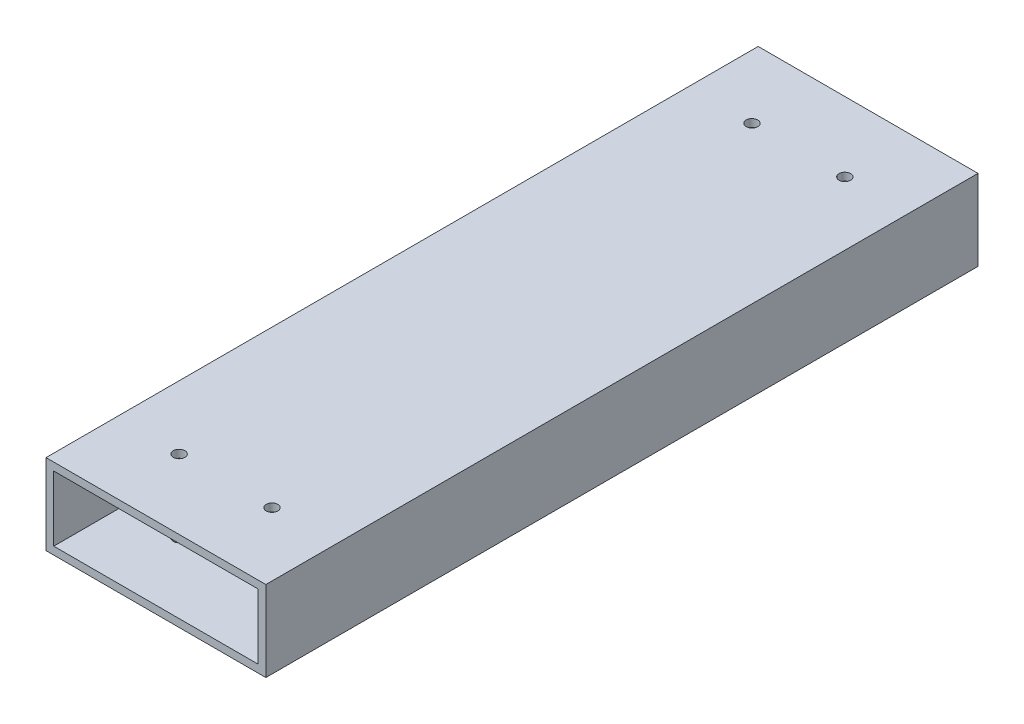
from build123d import *

# Parameters (mm, degrees)
CROQUIS1_W              = 56.8
CROQUIS1_H              = 20.82
SALIENTE_EXTRUIR1_DEPTH = 184
CROQUIS5_W              = 52.8
CROQUIS5_H              = 16.82
CORTAR_EXTRUIR5_DEPTH   = 184
CROQUIS6_R              = 1.5
CORTAR_EXTRUIR6_DEPTH   = 26


with BuildPart() as part:
    # Croquis1 → Saliente-Extruir1 (new body)
    with BuildSketch(Plane.XY):
        with Locations((8.738488477, -207.47377213)):
            Rectangle(CROQUIS1_W, CROQUIS1_H)
    extrude(amount=SALIENTE_EXTRUIR1_DEPTH)

    # Croquis5 → Cortar-Extruir5 (cut)
    with BuildSketch(Plane(origin=(0, 0, 0), x_dir=(-1, 0, 0), z_dir=(0, 0, -1))):
        with Locations((-8.738488477, -207.47377213)):
            Rectangle(CROQUIS5_W, CROQUIS5_H)
    extrude(amount=-CORTAR_EXTRUIR5_DEPTH, mode=Mode.SUBTRACT)

    # Croquis6 → Cortar-Extruir6 (cut)
    with BuildSketch(Plane(origin=(0, -197.06377213, 0), x_dir=(1, 0, 0), z_dir=(0, 1, 0))):
        with Locations((-3.261511523, -18)):
            Circle(CROQUIS6_R)
        with Locations((20.738488477, -18)):
            Circle(CROQUIS6_R)
        with Locations((-3.261511523, -166)):
            Circle(CROQUIS6_R)
        with Locations((20.738488477, -166)):
            Circle(CROQUIS6_R)
    extrude(amount=-CORTAR_EXTRUIR6_DEPTH, mode=Mode.SUBTRACT)


solid = part.part
